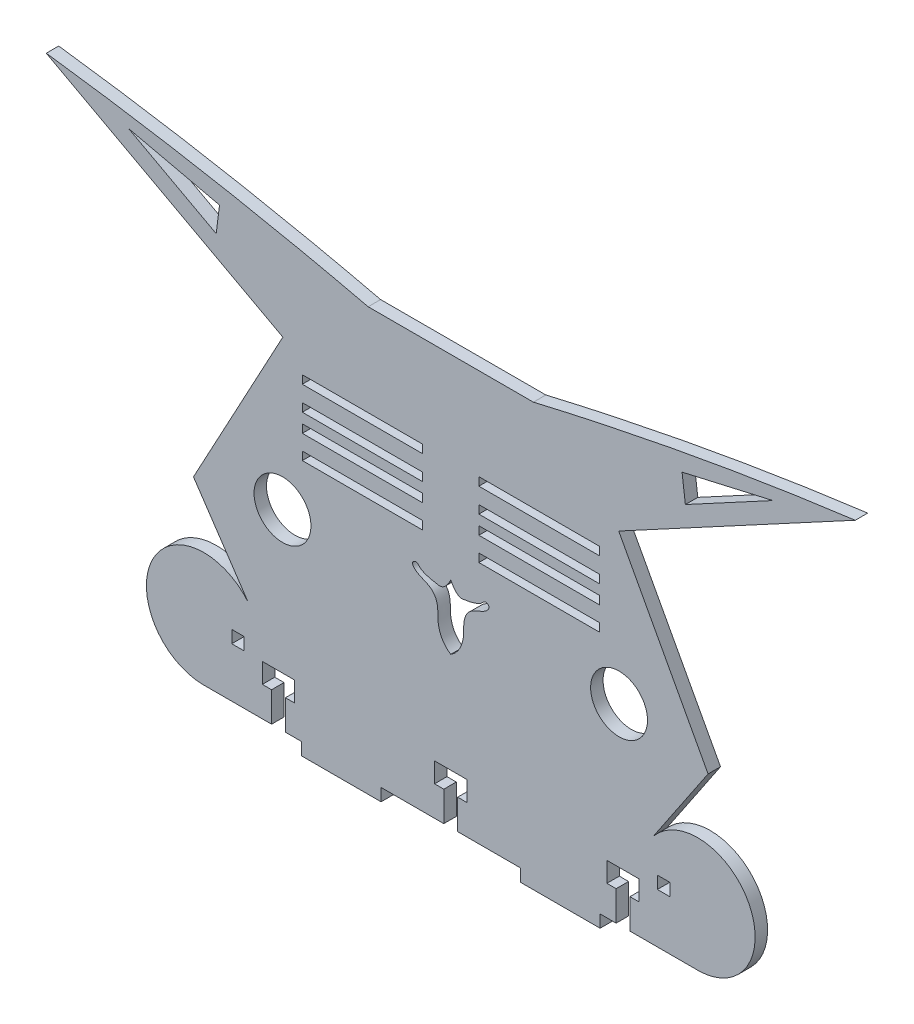
from build123d import *

# Parameters (mm, degrees)
BOSS_EXTRUDE1_DEPTH = 3.175
SKETCH6_R           = 7.257154646
CUT_EXTRUDE5_DEPTH  = 3.175
SKETCH9_W           = 3.175
SKETCH9_H           = 3.175
CUT_EXTRUDE7_DEPTH  = 3.175
SKETCH8_W           = 30.724562626
SKETCH8_H           = 2.108548415
SKETCH8_H_2         = 2.108548416
CUT_EXTRUDE6_DEPTH  = 3.175
SKETCH10_W          = 20.32
SKETCH10_H          = 3.175
BOSS_EXTRUDE2_DEPTH = 3.175
CUT_EXTRUDE8_DEPTH  = 3.175


with BuildPart() as part:
    # Sketch1 → Boss-Extrude1 (new body)
    with BuildSketch(Plane.XY):
        with BuildLine():
            Line((41.839101774, 27.787790455), (102.197242912, 60.347139319))
            add(Edge.make_bspline(
                [(102.197242912, 60.347139319), (60.742723961, 54.966910385), (20.07049128, 45.384405553)],
                knots=[0, 0, 0, 1, 1, 1], degree=2))
            Line((20.07049128, 45.384405553), (-1.005398806, 45.384405553))
            Line((-1.005398806, 45.384405553), (-1.005398806, -59.17809155))
            Line((-1.005398806, -59.17809155), (62.494601194, -59.17809155))
            ThreePointArc((62.494601194, -59.17809155), (75.141770938, -38.057520175), (50.68909305, -35.212176281))
            Line((50.68909305, -35.212176281), (64.64061298, -14.48138505))
            Line((64.64061298, -14.48138505), (41.839101774, 27.787790455))
        make_face()
    boss_extrude1 = extrude(amount=BOSS_EXTRUDE1_DEPTH)

    # Sketch6 → Cut-Extrude5 (cut)
    with BuildSketch(Plane.XY):
        with Locations((41.928309242, -10.363128131)):
            Circle(SKETCH6_R)
        Polygon((57.996590192, 48.887210307), (81.18043036, 54.194354442), (58.847058779, 42.146931793), align=None)
        with BuildLine():
            Line((-1.005398806, -4.460766145), (-1.005398806, -20.868472516))
            add(Edge.make_bspline(
                [(-1.005398806, -4.460766145), (0.91009084, -8.087601817), (2.163575929, -6.944318239), (3.759225089, -6.904333812), (6.982497489, -5.965665574), (7.107924345, -4.954032148), (8.383749268, -4.7792984), (8.858412265, -5.597884514), (8.059934477, -7.266476525), (5.387533009, -7.743309848), (2.87598619, -9.738386244), (2.165758509, -12.437670072), (2.502299568, -16.460193064), (0.929673731, -19.700918611), (-1.005398806, -20.868472516)],
                knots=[0, 0, 0, 0, 0.201890753, 0.228999657, 0.271089043, 0.343451588, 0.384030867, 0.405551279, 0.412267992, 0.551583373, 0.622208689, 0.702728492, 0.796795757, 1, 1, 1, 1], degree=3))
        make_face()
    cut_extrude5 = extrude(amount=CUT_EXTRUDE5_DEPTH, mode=Mode.SUBTRACT)

    # Sketch9 → Cut-Extrude7 (cut)
    with BuildSketch(Plane(origin=(0, 0, 0), x_dir=(-1, 0, 0), z_dir=(0, 0, -1))):
        with Locations((-53.287101194, -44.89059155)):
            Rectangle(SKETCH9_W, SKETCH9_H)
    cut_extrude7 = extrude(amount=-CUT_EXTRUDE7_DEPTH, mode=Mode.SUBTRACT)

    # Sketch8 → Cut-Extrude6 (cut)
    with BuildSketch(Plane.XY):
        with Locations((-23.52574119, 20.913238549)):
            Rectangle(SKETCH8_W, SKETCH8_H)
        with Locations((-23.52574119, 14.738203903)):
            Rectangle(SKETCH8_W, SKETCH8_H_2)
        with Locations((-23.52574119, 10.069275269)):
            Rectangle(SKETCH8_W, SKETCH8_H)
        with Locations((-23.52574119, 4.044851224)):
            Rectangle(SKETCH8_W, SKETCH8_H_2)
        with Locations((21.514943577, 4.044851224)):
            Rectangle(SKETCH8_W, SKETCH8_H_2)
        with Locations((21.514943577, 10.069275269)):
            Rectangle(SKETCH8_W, SKETCH8_H)
        with Locations((21.514943577, 14.738203903)):
            Rectangle(SKETCH8_W, SKETCH8_H_2)
        with Locations((21.514943577, 20.913238549)):
            Rectangle(SKETCH8_W, SKETCH8_H)
    cut_extrude6 = extrude(amount=CUT_EXTRUDE6_DEPTH, mode=Mode.SUBTRACT)

    # Mirror4: Boss-Extrude1, Cut-Extrude5, Cut-Extrude7, Cut-Extrude6 across plane
    add(boss_extrude1.mirror(Plane(origin=(-1.005398806, 0, 3.175), x_dir=(0, 0, 1), z_dir=(1, 0, 0))))
    add(cut_extrude5.mirror(Plane(origin=(-1.005398806, 0, 3.175), x_dir=(0, 0, 1), z_dir=(1, 0, 0))), mode=Mode.SUBTRACT)
    add(cut_extrude7.mirror(Plane(origin=(-1.005398806, 0, 3.175), x_dir=(0, 0, 1), z_dir=(1, 0, 0))), mode=Mode.SUBTRACT)
    add(cut_extrude6.mirror(Plane(origin=(-1.005398806, 0, 3.175), x_dir=(0, 0, 1), z_dir=(1, 0, 0))), mode=Mode.SUBTRACT)

    # Sketch10 → Boss-Extrude2 (add)
    with BuildSketch(Plane.XZ.offset(59.17809155)):
        with Locations((-28.945398806, 1.5875)):
            Rectangle(SKETCH10_W, SKETCH10_H)
        with Locations((26.934601194, 1.5875)):
            Rectangle(SKETCH10_W, SKETCH10_H)
    extrude(amount=BOSS_EXTRUDE2_DEPTH)

    # Sketch11 → Cut-Extrude8 (cut)
    with BuildSketch(Plane.XY.offset(3.175)):
        Polygon((-49.087598806, -51.55809155), (-49.087598806, -46.47809155), (-40.832598806, -46.47809155), (-40.832598806, -51.55809155), (-43.194798806, -51.55809155), (-43.194798806, -59.17809155), (-46.725398806, -59.17809155), (-46.725398806, -51.55809155), align=None)
        Polygon((-5.145598806, -51.55809155), (-5.145598806, -46.47809155), (3.109401194, -46.47809155), (3.109401194, -51.55809155), (0.747201194, -51.55809155), (0.747201194, -59.17809155), (-2.783398806, -59.17809155), (-2.783398806, -51.55809155), align=None)
        Polygon((38.821801194, -51.55809155), (38.821801194, -46.47809155), (47.076801194, -46.47809155), (47.076801194, -51.55809155), (44.714601194, -51.55809155), (44.714601194, -59.17809155), (41.184001194, -59.17809155), (41.184001194, -51.55809155), align=None)
    extrude(amount=-CUT_EXTRUDE8_DEPTH, mode=Mode.SUBTRACT)


solid = part.part
